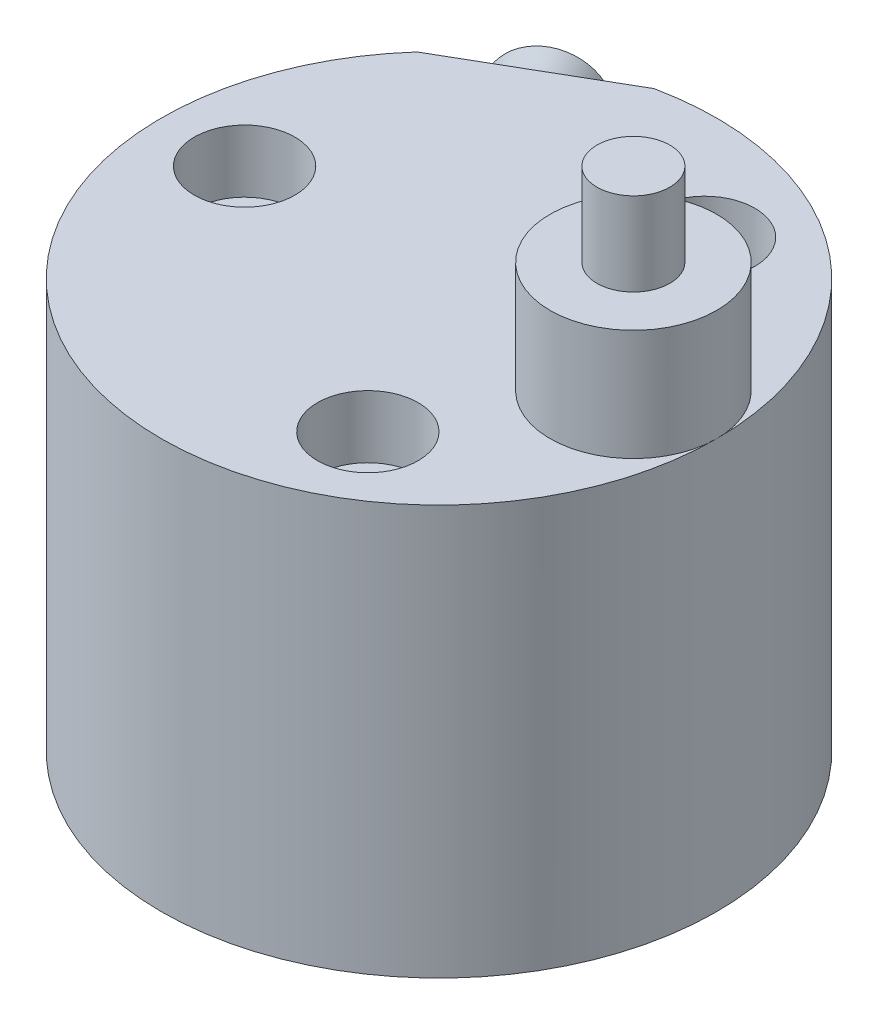
from build123d import *

# Parameters (mm, degrees)
SKETCH1_R          = 40
EXTRUDE1_DEPTH     = 59
SKETCH11_R         = 12
EXTRUDE2_DEPTH     = 16
SKETCH12_R         = 5.25
EXTRUDE3_DEPTH     = 12
HOLE1_D            = 9
HOLE1_DEPTH        = 59.001
HOLE1_CBORE_D      = 14.5
HOLE1_CBORE_DEPTH  = 9
CIRPATTERN1_COUNT  = 3
SKETCH5_R          = 4
CUT_EXTRUDE1_DEPTH = 4
SKETCH13_R         = 4
CUT_EXTRUDE5_DEPTH = 10
SKETCH6_R          = 5
CUT_EXTRUDE2_DEPTH = 3
SKETCH7_R          = 2
CUT_EXTRUDE3_DEPTH = 48.5
CUT_EXTRUDE6_DEPTH = 15.5
SKETCH8_W          = 15
SKETCH8_H          = 4.283
CUT_EXTRUDE4_DEPTH = 5


with BuildPart() as part:
    # Sketch1 → Extrude1 (new body)
    with BuildSketch(Plane(origin=(0, 0, 0), x_dir=(1, 0, 0), z_dir=(0, 1, 0))):
        with Locations(Location((0, 0, 0), (0, 0, 270))):  # turned: the seam where the file's is
            Circle(SKETCH1_R)
    extrude(amount=EXTRUDE1_DEPTH)

    # Sketch11 → Extrude2 (add)
    with BuildSketch(Plane(origin=(0, 59, 0), x_dir=(1, 0, 0), z_dir=(0, 1, 0))):
        with Locations((28, 0)):
            Circle(SKETCH11_R)
    extrude(amount=EXTRUDE2_DEPTH)

    # Sketch12 → Extrude3 (add)
    with BuildSketch(Plane(origin=(0, 75, 0), x_dir=(1, 0, 0), z_dir=(0, 1, 0))):
        with Locations(Location((28, 0, 0), (0, 0, 270))):  # turned: the seam where the file's is
            Circle(SKETCH12_R)
    extrude(amount=EXTRUDE3_DEPTH)

    # Hole1
    with Locations(Plane(origin=(0, 59, 0), x_dir=(-1, 0, 0), z_dir=(0, 1, 0))):
        with Locations((28, 0)):
            hole1 = CounterBoreHole(HOLE1_D / 2, HOLE1_CBORE_D / 2, HOLE1_CBORE_DEPTH, depth=HOLE1_DEPTH)

    # CirPattern1: Hole1 ×3 about axis
    cirpattern1_axis = Axis((0, 0, 0), (0, 1, 0))
    for i in range(1, CIRPATTERN1_COUNT):
        add(hole1.rotate(cirpattern1_axis, i * 360 / CIRPATTERN1_COUNT), mode=Mode.SUBTRACT)

    # Sketch5 → Cut-Extrude1 (cut)
    with BuildSketch(Plane.XZ):
        with Locations(Location((0, 0, 0), (0, 0, 270))):  # turned: the seam where the file's is
            Circle(SKETCH5_R)
    extrude(amount=-CUT_EXTRUDE1_DEPTH, mode=Mode.SUBTRACT)

    # Sketch13 → Cut-Extrude5 (cut)
    with BuildSketch(Plane.XZ):
        with Locations(Location((-14, 24.248711306, 0), (0, 0, 270))):  # turned: the seam where the file's is
            Circle(SKETCH13_R)
    extrude(amount=-CUT_EXTRUDE5_DEPTH, mode=Mode.SUBTRACT)

    # Sketch6 → Cut-Extrude2 (cut)
    with BuildSketch(Plane.XZ):
        with Locations(Location((-14, -24.248711306, 0), (0, 0, 270))):  # turned: the seam where the file's is
            Circle(SKETCH6_R)
    extrude(amount=-CUT_EXTRUDE2_DEPTH, mode=Mode.SUBTRACT)

    # Sketch7 → Cut-Extrude3 (cut)
    with BuildSketch(Plane.XZ.offset(-3)):
        with Locations(Location((-14, -24.248711306, 0), (0, 0, 270))):  # turned: the seam where the file's is
            Circle(SKETCH7_R)
    extrude(amount=-CUT_EXTRUDE3_DEPTH, mode=Mode.SUBTRACT)

    # Sketch14 → Cut-Extrude6 (cut)
    with BuildSketch(Plane(origin=(0, 59, 0), x_dir=(1, 0, 0), z_dir=(0, 1, 0))):
        with BuildLine():
            Line((-29.816653826, 26.663967345), (-8.183346174, 39.153963342))
            ThreePointArc((-8.183346174, 39.153963342), (-20, 34.641016151), (-29.816653826, 26.663967345))
        make_face()
    extrude(amount=-CUT_EXTRUDE6_DEPTH, mode=Mode.SUBTRACT)

    # Sketch8 → Cut-Revolve1 (revolve, cut)
    with BuildSketch(Plane(origin=(0, 0, 0), x_dir=(-0.5, 0, -0.866025404), z_dir=(0.866025404, 0, -0.5)), mode=Mode.PRIVATE) as cut_revolve1_sk:
        with Locations((30.5, 49.3585)):
            Rectangle(SKETCH8_W, SKETCH8_H)
    revolve(cut_revolve1_sk.sketch.rotate(Axis((-25.792798991, 51.5, -44.674438322), (0.5, 0, 0.866025404)), 270), axis=Axis((-25.792798991, 51.5, -44.674438322), (0.5, 0, 0.866025404)), mode=Mode.SUBTRACT)  # turned: the seam where the file's is

    # Sketch9 → Revolve2 (revolve)
    with BuildSketch(Plane(origin=(0, 0, 0), x_dir=(-0.5, 0, -0.866025404), z_dir=(0.866025404, 0, -0.5)), mode=Mode.PRIVATE) as revolve2_sk:
        Polygon((38, 44.5), (38, 47.217), (31.419, 47.217), (31, 47.636), (31, 51.5), (43, 51.5), (43, 44.5), align=None)
    revolve(revolve2_sk.sketch.rotate(Axis((-23.293952485, 51.5, -40.346309212), (0.5, 0, 0.866025404)), 270), axis=Axis((-23.293952485, 51.5, -40.346309212), (0.5, 0, 0.866025404)))  # turned: the seam where the file's is

    # Sketch10 → Cut-Extrude4 (cut)
    with BuildSketch(Plane(origin=(-21.5, 0, -37.239092363), x_dir=(-0.866025404, 0, 0.5), z_dir=(-0.5, 0, -0.866025404))):
        Polygon((2.886751346, 51.5), (1.443375673, 54), (-1.443375673, 54), (-2.886751346, 51.5), (-1.443375673, 49), (1.443375673, 49), align=None)
    extrude(amount=-CUT_EXTRUDE4_DEPTH, mode=Mode.SUBTRACT)


solid = part.part
